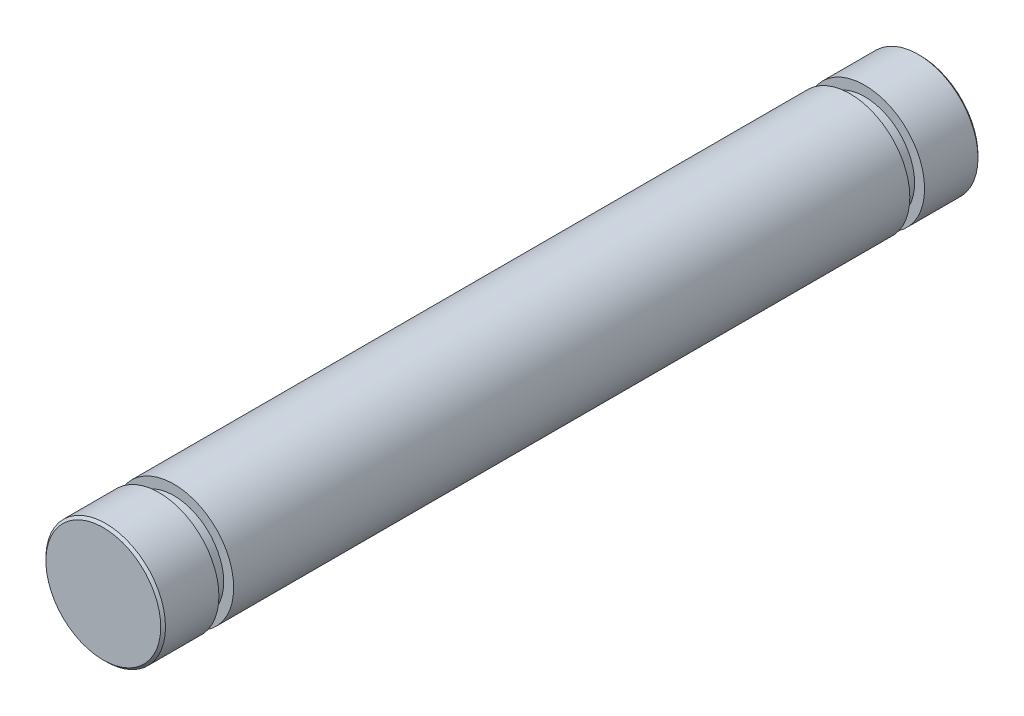
from build123d import *

# Parameters (mm, degrees)
SKETCH2_R                = 3
BOSS_EXTRUDE1_DEPTH      = 20.5
BOSS_EXTRUDE1_DEPTH_BACK = 20.5
CHAMFER1_SIZE            = 0.12
CUT_EXTRUDE1_START       = -2.1
SKETCH3_R                = 3
SKETCH3_R_2              = 2.5
CUT_EXTRUDE1_DEPTH       = 0.74


with BuildPart() as part:
    # Sketch2 → Boss-Extrude1 (new body, two sides)
    with BuildSketch(Plane.XY) as boss_extrude1_sk:
        Circle(SKETCH2_R)
    extrude(amount=BOSS_EXTRUDE1_DEPTH)
    extrude(boss_extrude1_sk.sketch, amount=-BOSS_EXTRUDE1_DEPTH_BACK)

    # Chamfer1
    chamfer1_edges = [part.edges().sort_by_distance(p)[0] for p in [
        (-3, 0, -20.5),
        (-3, 0, 20.5),
    ]]
    chamfer(chamfer1_edges, length=CHAMFER1_SIZE)

    # Sketch3 → Cut-Extrude1 (cut)
    with BuildSketch(Plane.XY.offset(19.8).offset(CUT_EXTRUDE1_START)):
        Circle(SKETCH3_R)
        Circle(SKETCH3_R_2, mode=Mode.SUBTRACT)
    cut_extrude1 = extrude(amount=-CUT_EXTRUDE1_DEPTH, mode=Mode.SUBTRACT)

    # Mirror1: Cut-Extrude1 across plane
    add(cut_extrude1.mirror(Plane.XY), mode=Mode.SUBTRACT)


solid = part.part
